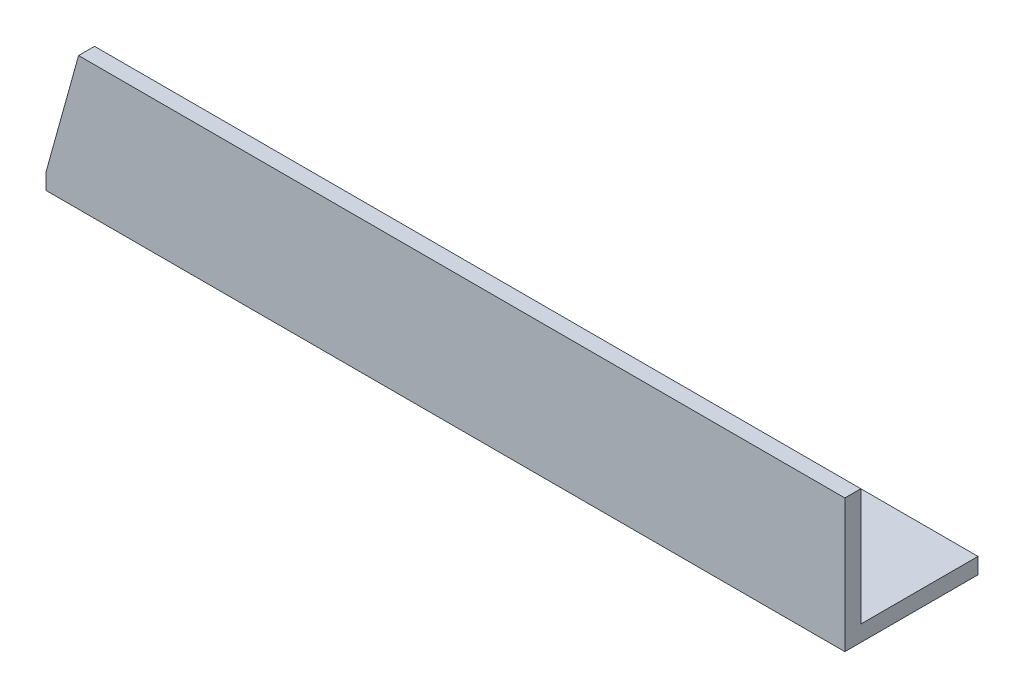
from build123d import *

# Parameters (mm, degrees)
EXTRUDE_1_DEPTH     = 300
CUT_EXTRUDE_1_DEPTH = 51


with BuildPart() as part:
    # Эскиз1 → Вытянуть-Тонкостенный1 (new body)
    with BuildSketch(Plane(origin=(0, 0, 0), x_dir=(0, 0, -1), z_dir=(1, 0, 0))):
        Polygon((0, 50), (0, 0), (50, 0), (50, 6), (6, 6), (6, 50), align=None)
    extrude(amount=EXTRUDE_1_DEPTH)

    # Эскиз2 → Вырез-Вытянуть1 (cut, through all)
    with BuildSketch(Plane.XY):
        Polygon((0, 50), (12.226487967, 50), (0, 6), align=None)
    extrude(amount=-CUT_EXTRUDE_1_DEPTH, mode=Mode.SUBTRACT)


solid = part.part
